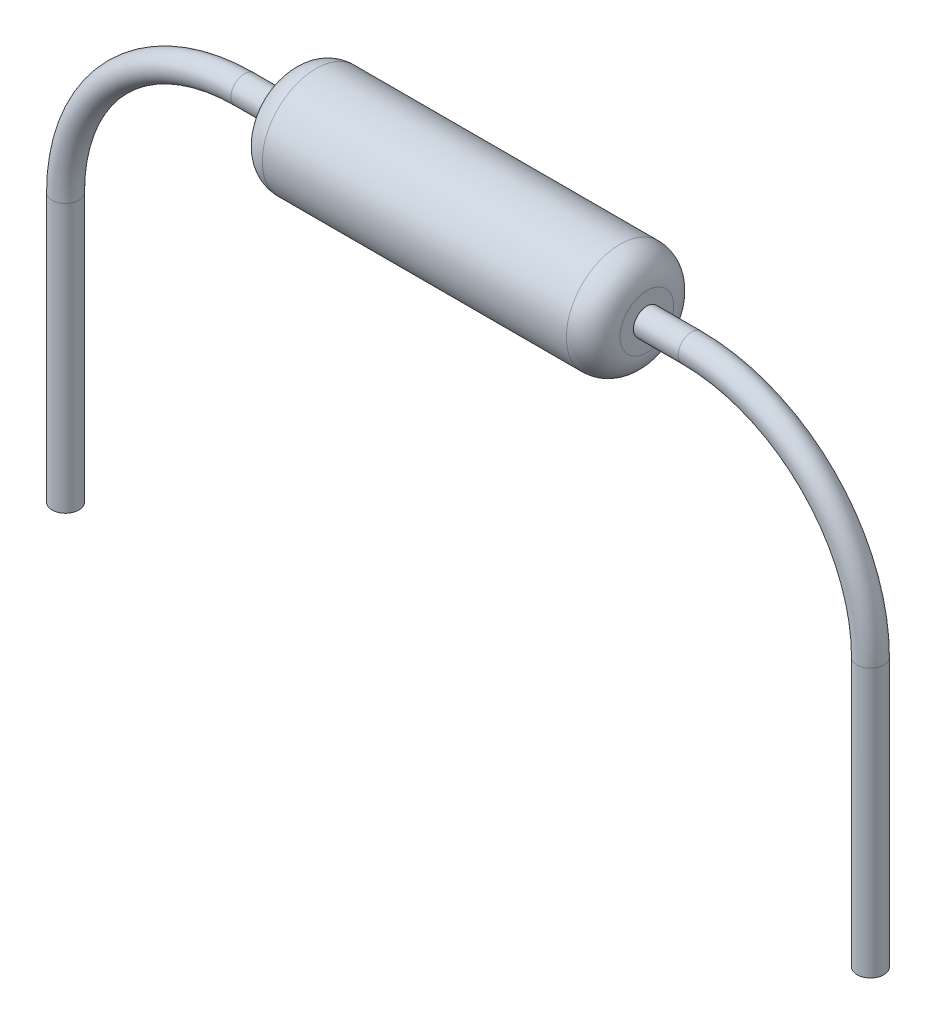
from build123d import *

# Parameters (mm, degrees)
SKETCH1_W               = 3.5
SKETCH1_H               = 0.35
FILLET1_R               = 0.1
SKETCH2_W               = 1.1
SKETCH2_H               = 0.55
SKETCH3_R               = 0.15
SKETCH6_W               = 10
SKETCH6_H               = 2.5
CUT_EXTRUDE1_DEPTH      = 1.6000001
CUT_EXTRUDE1_DEPTH_BACK = 1.6000001


with BuildPart() as part:
    # Sketch1 → Base-Revolve (revolve)
    with BuildSketch(Plane.XY, mode=Mode.PRIVATE) as base_revolve_sk:
        with Locations((0, 0.175)):
            Rectangle(SKETCH1_W, SKETCH1_H)
    revolve(base_revolve_sk.sketch.rotate(Axis((-19.951848249, 0, 0), (1, 0, 0)), 90), axis=Axis((-19.951848249, 0, 0), (1, 0, 0)))  # turned: the seam where the file's is

    # Fillet1
    fillet1_edges = [part.edges().sort_by_distance(p)[0] for p in [
        (1.75, 0, -0.35),
        (-1.75, 0, -0.35),
    ]]
    fillet(fillet1_edges, radius=FILLET1_R)

    # Sketch2 → Boss-Revolve1 (revolve)
    with BuildSketch(Plane.XY, mode=Mode.PRIVATE) as boss_revolve1_sk:
        with Locations((0.7, 0.275)):
            Rectangle(SKETCH2_W, SKETCH2_H)
    revolve(boss_revolve1_sk.sketch.rotate(Axis((0, 0, 0), (1, 0, 0)), 90), axis=Axis((0, 0, 0), (1, 0, 0)))  # turned: the seam where the file's is

    # Boss-Sweep1: sweep along a path in Sketch4
    with BuildLine(Plane.XY) as boss_sweep1_path:
        Line((0.174016429, -7), (-2.5, -7))
        ThreePointArc((-2.5, -7), (-3.914213562, -6.414213562), (-4.5, -5))
        Line((-4.5, -5), (-4.5, -2))
        ThreePointArc((-4.5, -2), (-3.914213562, -0.585786438), (-2.5, 0))
        Line((-2.5, 0), (2.5, 0))
        ThreePointArc((2.5, 0), (3.914213562, -0.585786438), (4.5, -2))
        Line((4.5, -2), (4.5, -5))
        ThreePointArc((4.5, -5), (3.914213562, -6.414213562), (2.5, -7))
        Line((2.5, -7), (0.174016429, -7))
    # Sketch3 → Boss-Sweep1 (sweep)
    with BuildSketch(Plane(origin=(0, 0, 0), x_dir=(0, 0, -1), z_dir=(1, 0, 0))):
        with Locations((0, -7)):
            Circle(SKETCH3_R)
    sweep(path=boss_sweep1_path.line)

    # Sketch5 → Boss-Revolve2 (revolve)
    with BuildSketch(Plane.XY):
        with BuildLine():
            Line((-1.7, 0.6), (1.7, 0.6))
            ThreePointArc((1.7, 0.6), (1.912132034, 0.512132034), (2, 0.3))
            Line((2, 0.3), (2, 0))
            Line((2, 0), (1.955, 0))
            Line((1.955, 0), (1.955, 0.3))
            ThreePointArc((1.955, 0.3), (1.880312229, 0.480312229), (1.7, 0.555))
            Line((1.7, 0.555), (-1.7, 0.555))
            ThreePointArc((-1.7, 0.555), (-1.880312229, 0.480312229), (-1.955, 0.3))
            Line((-1.955, 0.3), (-1.955, 0))
            Line((-1.955, 0), (-2, 0))
            Line((-2, 0), (-2, 0.3))
            ThreePointArc((-2, 0.3), (-1.912132034, 0.512132034), (-1.7, 0.6))
        make_face()
    revolve(axis=Axis((2, 0, 0), (-1, 0, 0)))

    # Sketch6 → Cut-Extrude1 (cut, two sides)
    with BuildSketch(Plane.XY) as cut_extrude1_sk:
        with Locations((0, -6.25)):
            Rectangle(SKETCH6_W, SKETCH6_H)
    extrude(amount=CUT_EXTRUDE1_DEPTH, mode=Mode.SUBTRACT)
    extrude(cut_extrude1_sk.sketch, amount=-CUT_EXTRUDE1_DEPTH_BACK, mode=Mode.SUBTRACT)


solid = part.part
